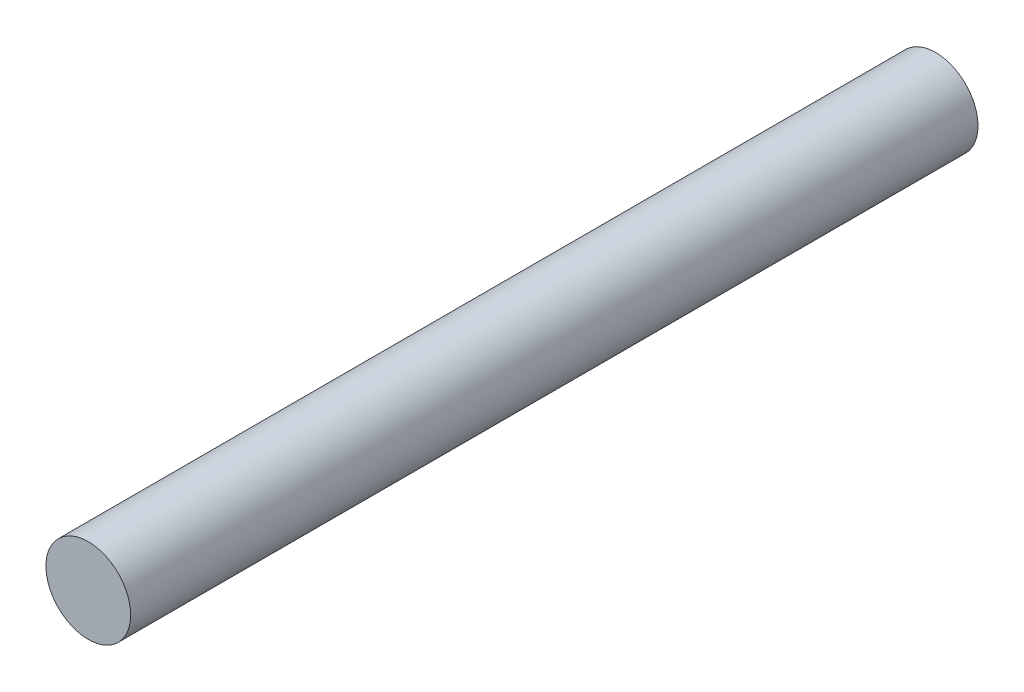
from build123d import *

# Parameters (mm, degrees)
SKETCH1_R           = 0.5
BOSS_EXTRUDE1_DEPTH = 10


with BuildPart() as part:
    # Sketch1 → Boss-Extrude1 (new body)
    with BuildSketch(Plane.XY):
        Circle(SKETCH1_R)
    extrude(amount=BOSS_EXTRUDE1_DEPTH)


solid = part.part
